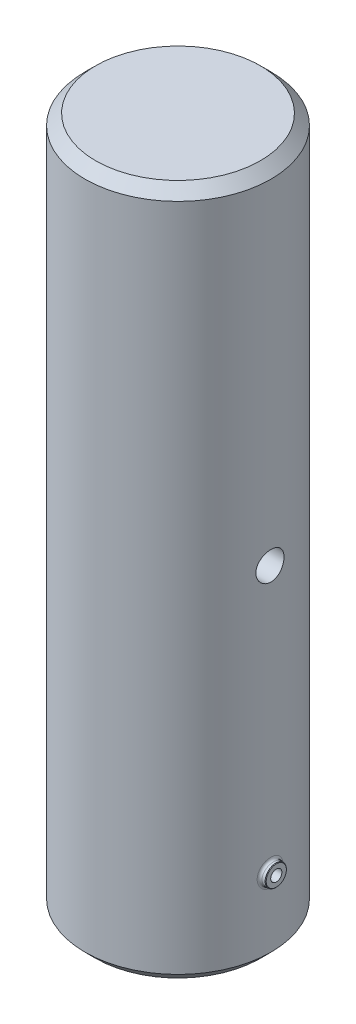
from build123d import *

# Parameters (mm, degrees)
ESQUISSE1_R             = 17.5
ESQUISSE1_R_2           = 12.5
BOSS_EXTRU_1_DEPTH      = 65
ESQUISSE3_R             = 2.65
ENL_V_MAT_EXTRU_1_DEPTH = 4
ESQUISSE4_R             = 2
BOSS_EXTRU_2_DEPTH      = 1
BOSS_EXTRU_2_DEPTH_BACK = 2
ENL_V_MAT_EXTRU_2_REACH = 38
ESQUISSE5_R             = 1.05
ENL_V_START             = -3.5
ESQUISSE6_R             = 2.5
ENL_V_MAT_EXTRU_3_DEPTH = 5
CONG_1_R                = 0.5
CHANFREIN1_SIZE         = 0.1
ESQUISSE7_R             = 17.5
BOSS_EXTRU_3_DEPTH      = 5
CHANFREIN2_SIZE         = 2
CHANFREIN3_SIZE         = 1
CHANFREIN3_SIZE2        = 0.577350269


with BuildPart() as part:
    # Esquisse1 → Boss.-Extru.1 (new body, symmetric)
    with BuildSketch(Plane(origin=(0, 0, 0), x_dir=(1, 0, 0), z_dir=(0, 1, 0))):
        Circle(ESQUISSE1_R)
        Circle(ESQUISSE1_R_2, mode=Mode.SUBTRACT)
    extrude(amount=BOSS_EXTRU_1_DEPTH, both=True)

    # Esquisse3 → Enlèv. mat.-Extru.1 (cut)
    with BuildSketch(Plane(origin=(17.5, 0, 0), x_dir=(0, 0, -1), z_dir=(1, 0, 0))):
        Circle(ESQUISSE3_R)
    enl_v_mat_extru_1 = extrude(amount=-ENL_V_MAT_EXTRU_1_DEPTH, mode=Mode.SUBTRACT)

    # Symétrie1: Enlèv. mat.-Extru.1 across plane
    add(enl_v_mat_extru_1.mirror(Plane(origin=(0, 0, 0), x_dir=(0, 0, 1), z_dir=(1, 0, 0))), mode=Mode.SUBTRACT)

    # Esquisse4 → Boss.-Extru.2 (add, two sides)
    with BuildSketch(Plane(origin=(17.5, 0, 0), x_dir=(0, 0, -1), z_dir=(1, 0, 0))) as boss_extru_2_sk:
        with Locations((0, -50)):
            Circle(ESQUISSE4_R)
    extrude(amount=BOSS_EXTRU_2_DEPTH)
    extrude(boss_extru_2_sk.sketch, amount=-BOSS_EXTRU_2_DEPTH_BACK)

    # Esquisse5 → Enlèv. mat.-Extru.2 (cut, up to next)
    with BuildSketch(Plane(origin=(18.5, 0, 0), x_dir=(0, 0, -1), z_dir=(1, 0, 0)), mode=Mode.PRIVATE) as enl_v_mat_extru_2_sk1:
        with Locations((0, -50)):
            Circle(ESQUISSE5_R)
    enl_v_mat_extru_2_tool1 = extrude(enl_v_mat_extru_2_sk1.sketch, amount=-ENL_V_MAT_EXTRU_2_REACH, mode=Mode.PRIVATE) & part.part
    add(enl_v_mat_extru_2_tool1.solids().sort_by_distance((18.5, -50, 0))[0], mode=Mode.SUBTRACT)

    # Esquisse6 → Enlèv. mat.-Extru.3 (cut)
    with BuildSketch(Plane(origin=(18.5, 0, 0), x_dir=(0, 0, -1), z_dir=(1, 0, 0)).offset(ENL_V_START)):
        with Locations((0, -50)):
            Circle(ESQUISSE6_R)
    extrude(amount=-ENL_V_MAT_EXTRU_3_DEPTH, mode=Mode.SUBTRACT)

    # Congé1
    cong_1_edges = [part.edges().sort_by_distance(p)[0] for p in [
        (17.385338651, -50, 2),
    ]]
    fillet(cong_1_edges, radius=CONG_1_R)

    # Chanfrein1
    chanfrein1_edges = [part.edges().sort_by_distance(p)[0] for p in [
        (18.5, -50, 2),
    ]]
    chamfer(chanfrein1_edges, length=CHANFREIN1_SIZE)

    # Esquisse7 → Boss.-Extru.3 (add)
    with BuildSketch(Plane(origin=(0, 65, 0), x_dir=(1, 0, 0), z_dir=(0, 1, 0))):
        Circle(ESQUISSE7_R)
    extrude(amount=-BOSS_EXTRU_3_DEPTH)

    # Chanfrein2
    chanfrein2_edges = [part.edges().sort_by_distance(p)[0] for p in [
        (-17.5, -65, 0),
        (-17.5, 65, 0),
    ]]
    chamfer(chanfrein2_edges, length=CHANFREIN2_SIZE)

    # Chanfrein3
    chanfrein3_edges = [part.edges().sort_by_distance(p)[0] for p in [
        (-12.5, -65, 0),
    ]]
    chanfrein3_side = [part.faces().sort_by_distance(p)[0] for p in [
        (-12.5, -2.5, 0),
    ]]
    chamfer(chanfrein3_edges, length=CHANFREIN3_SIZE, length2=CHANFREIN3_SIZE2, reference=chanfrein3_side[0])


solid = part.part
